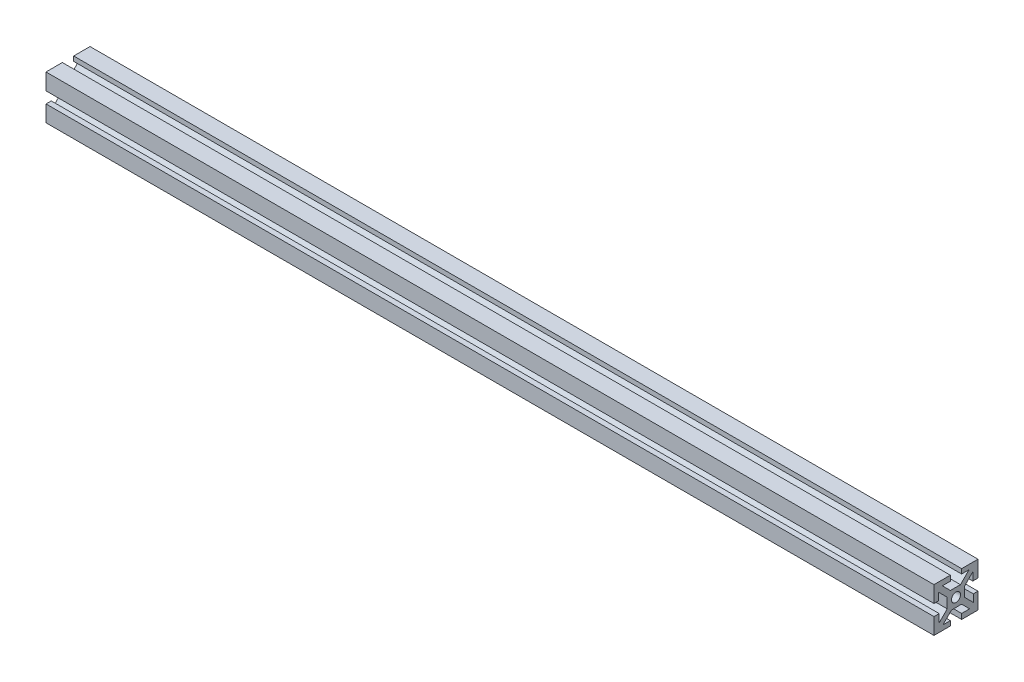
from build123d import *

# Parameters (mm, degrees)
SKETCH1_R           = 2.605
BOSS_EXTRUDE1_DEPTH = 508
CIRPATTERN1_COUNT   = 4


with BuildPart() as part:
    # Sketch1 → Boss-Extrude1 (new body)
    with BuildSketch(Plane(origin=(0, 0, 0), x_dir=(0, 0, -1), z_dir=(1, 0, 0))):
        Polygon((5, -5), (5, 3.203948776), (9.596194078, 7.800142853), (9.596194078, 3.24), (12.596194078, 3.24), (12.596194078, 12.596194078), (3.24, 12.596194078), (3.24, 9.921463197), (7.474873734, 9.921463197), (2.553410537, 5), (-5, 5), (-5, -5), align=None)
        Circle(SKETCH1_R, mode=Mode.SUBTRACT)
    boss_extrude1 = extrude(amount=BOSS_EXTRUDE1_DEPTH)

    # CirPattern1: Boss-Extrude1 ×4 about axis
    cirpattern1_axis = Axis((0, 0, 0), (1, 0, 0))
    for i in range(1, CIRPATTERN1_COUNT):
        add(boss_extrude1.rotate(cirpattern1_axis, i * 360 / CIRPATTERN1_COUNT))


solid = part.part
